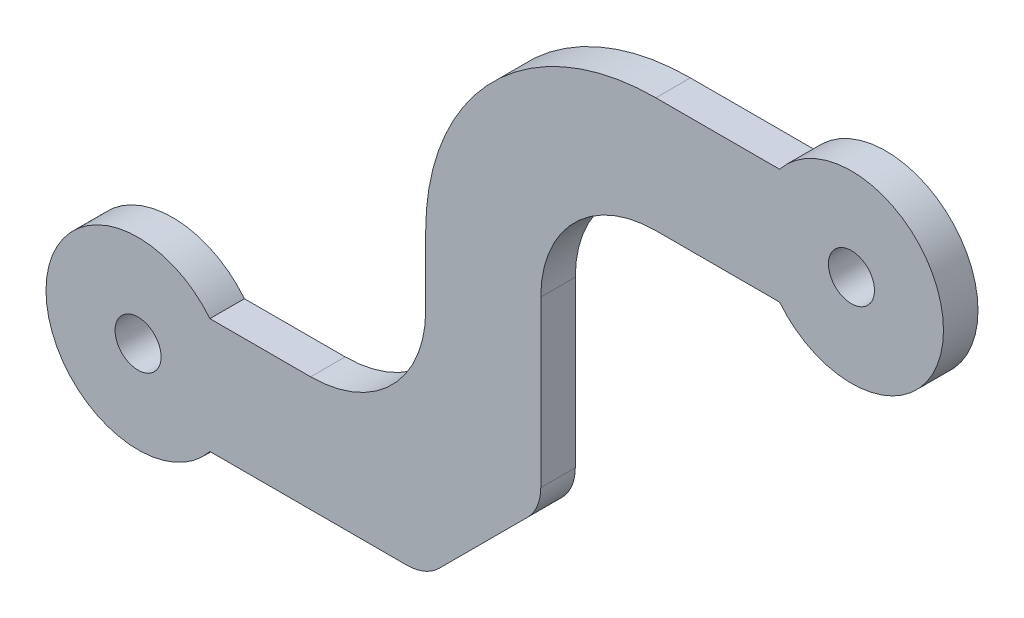
from build123d import *

# Parameters (mm, degrees)
SKETCH1_R           = 1
BOSS_EXTRUDE1_DEPTH = 1.5
FILLET1_R           = 10
FILLET2_R           = 5
FILLET3_R           = 5
CHAMFER1_SIZE       = 5
FILLET4_R           = 2


with BuildPart() as part:
    # Sketch1 → Boss-Extrude1 (new body)
    with BuildSketch(Plane.XY):
        with BuildLine():
            Line((3.122498999, 2.5), (12.5, 2.5))
            Line((12.5, 2.5), (12.5, 20.5))
            Line((12.5, 20.5), (27.877501001, 20.5))
            ThreePointArc((27.877501001, 20.5), (35, 18), (27.877501001, 15.5))
            Line((27.877501001, 15.5), (17.5, 15.5))
            Line((17.5, 15.5), (17.5, -2.5))
            Line((17.5, -2.5), (3.122498999, -2.5))
            ThreePointArc((3.122498999, -2.5), (-4, 0), (3.122498999, 2.5))
        make_face()
        Circle(SKETCH1_R, mode=Mode.SUBTRACT)
        with Locations((31, 18)):
            Circle(SKETCH1_R, mode=Mode.SUBTRACT)
    extrude(amount=BOSS_EXTRUDE1_DEPTH)

    # Fillet1
    fillet1_edges = [part.edges().sort_by_distance(p)[0] for p in [
        (12.5, 20.5, 0.75),
    ]]
    fillet(fillet1_edges, radius=FILLET1_R)

    # Fillet2
    fillet2_edges = [part.edges().sort_by_distance(p)[0] for p in [
        (17.5, 15.5, 0.75),
    ]]
    fillet(fillet2_edges, radius=FILLET2_R)

    # Fillet3
    fillet3_edges = [part.edges().sort_by_distance(p)[0] for p in [
        (12.5, 2.5, 0.75),
    ]]
    fillet(fillet3_edges, radius=FILLET3_R)

    # Chamfer1
    chamfer1_edges = [part.edges().sort_by_distance(p)[0] for p in [
        (17.5, -2.5, 0.75),
    ]]
    chamfer(chamfer1_edges, length=CHAMFER1_SIZE)

    # Fillet4
    fillet4_edges = [part.edges().sort_by_distance(p)[0] for p in [
        (17.5, 2.5, 0.75),
        (12.5, -2.5, 0.75),
    ]]
    fillet(fillet4_edges, radius=FILLET4_R)


solid = part.part
